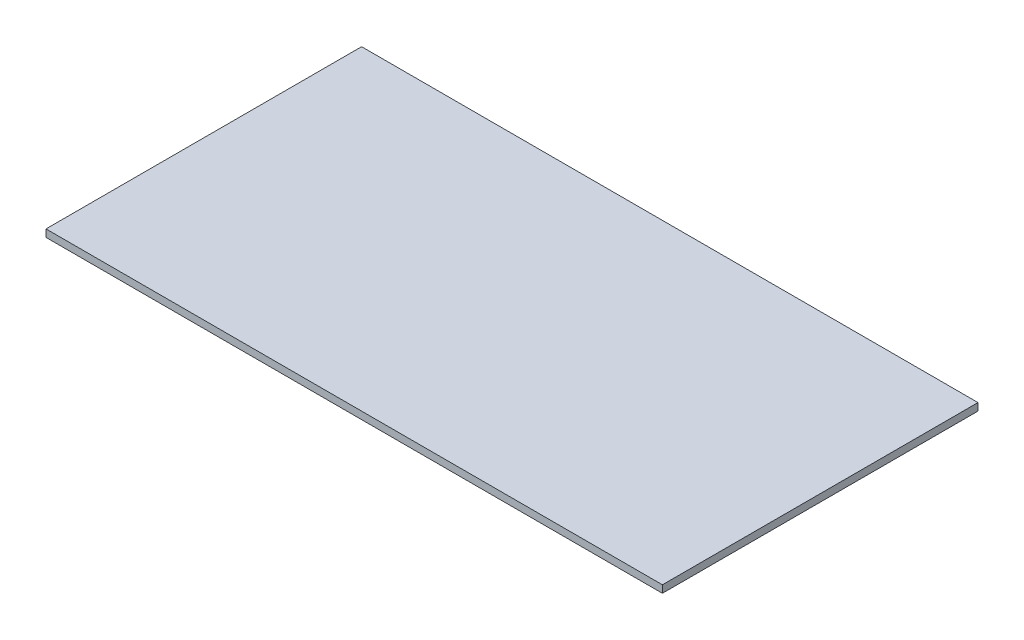
from build123d import *

# Parameters (mm, degrees)
SKETCH1_W           = 250
SKETCH1_H           = 128
BOSS_EXTRUDE1_DEPTH = 3


with BuildPart() as part:
    # Sketch1 → Boss-Extrude1 (new body)
    with BuildSketch(Plane(origin=(0, 0, 0), x_dir=(1, 0, 0), z_dir=(0, 1, 0))):
        with Locations((125, 64)):
            Rectangle(SKETCH1_W, SKETCH1_H)
    extrude(amount=BOSS_EXTRUDE1_DEPTH)


solid = part.part
